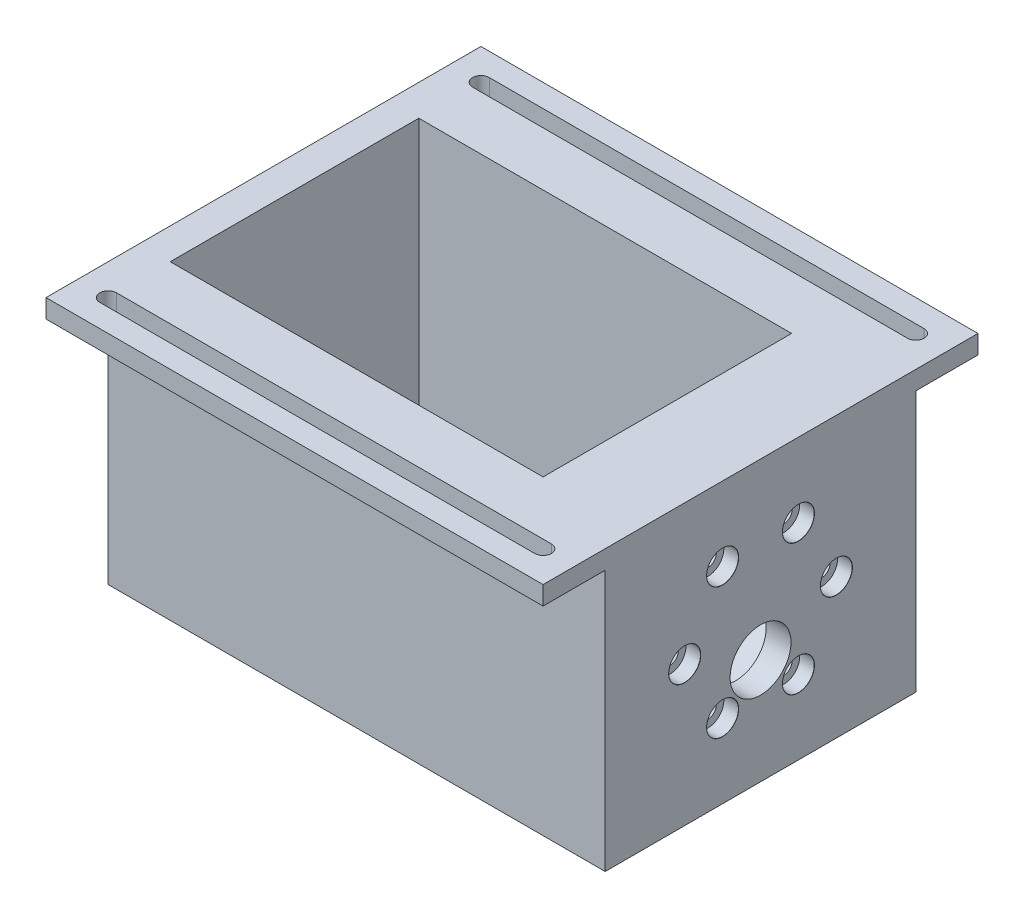
from build123d import *

# Parameters (mm, degrees)
SKETCH1_W                     = 101.6
SKETCH1_H                     = 63.5
BOSS_EXTRUDE1_DEPTH           = 57.15
CBORE_FOR_M3_SHCS1_AT_2_COUNT = 2
CBORE_FOR_M3_SHCS1_AT_2_PITCH = 15.499969
CBORE_FOR_M3_SHCS1_AT_3_COUNT = 2
CBORE_FOR_M3_SHCS1_AT_3_PITCH = 26.846733824
CBORE_FOR_M3_SHCS1_AT_4_COUNT = 2
CBORE_FOR_M3_SHCS1_AT_4_PITCH = 30.999938
CBORE_FOR_M3_SHCS1_AT_5_COUNT = 2
CBORE_FOR_M3_SHCS1_AT_5_PITCH = 26.846733824
CBORE_FOR_M3_SHCS1_AT_6_COUNT = 2
CBORE_FOR_M3_SHCS1_AT_6_PITCH = 15.499969
SKETCH8_R                     = 6.223
CUT_EXTRUDE1_DEPTH            = 50.8
SKETCH9_W                     = 76.2
SKETCH9_H                     = 50.8
CUT_EXTRUDE2_DEPTH            = 53.34
CUT_EXTRUDE3_START            = -19.05
SKETCH2_R                     = 18.542
CUT_EXTRUDE3_DEPTH            = 13.97
SKETCH10_W                    = 101.6
SKETCH10_H                    = 12.7
BOSS_EXTRUDE2_DEPTH           = 3.81
CUT_EXTRUDE4_DEPTH            = 3.81


with BuildPart() as part:
    # Sketch1 → Boss-Extrude1 (new body)
    with BuildSketch(Plane(origin=(0, 0, 0), x_dir=(1, 0, 0), z_dir=(0, 1, 0))):
        Rectangle(SKETCH1_W, SKETCH1_H)
    extrude(amount=BOSS_EXTRUDE1_DEPTH)

    # Sketch6 → CBORE for M3 SHCS1 (revolve, cut)
    with BuildSketch(Plane(origin=(50.8, 41.998366912, 7.7499845), x_dir=(0, 0, -1), z_dir=(0, 1, 0))):
        Polygon((0, 0), (0, 6.101463052), (1.7, 5.08), (1.7, 3), (3.25, 3), (3.25, 0.025), (3.275, 0), align=None)
    cbore_for_m3_shcs1 = revolve(axis=Axis((57.15, 41.998366912, 7.7499845), (-1, 0, 0)), mode=Mode.SUBTRACT)

    # CBORE for M3 SHCS1 at 2: CBORE for M3 SHCS1 ×2
    with Locations(*[Vector(0, -0.866025404, 0.5) * (i * CBORE_FOR_M3_SHCS1_AT_2_PITCH) for i in range(1, CBORE_FOR_M3_SHCS1_AT_2_COUNT)]):
        add(cbore_for_m3_shcs1, mode=Mode.SUBTRACT)

    # CBORE for M3 SHCS1 at 3: CBORE for M3 SHCS1 ×2
    with Locations(*[(0, -i * CBORE_FOR_M3_SHCS1_AT_3_PITCH, 0) for i in range(1, CBORE_FOR_M3_SHCS1_AT_3_COUNT)]):
        add(cbore_for_m3_shcs1, mode=Mode.SUBTRACT)

    # CBORE for M3 SHCS1 at 4: CBORE for M3 SHCS1 ×2
    with Locations(*[Vector(0, -0.866025404, -0.5) * (i * CBORE_FOR_M3_SHCS1_AT_4_PITCH) for i in range(1, CBORE_FOR_M3_SHCS1_AT_4_COUNT)]):
        add(cbore_for_m3_shcs1, mode=Mode.SUBTRACT)

    # CBORE for M3 SHCS1 at 5: CBORE for M3 SHCS1 ×2
    with Locations(*[Vector(0, -0.5, -0.866025404) * (i * CBORE_FOR_M3_SHCS1_AT_5_PITCH) for i in range(1, CBORE_FOR_M3_SHCS1_AT_5_COUNT)]):
        add(cbore_for_m3_shcs1, mode=Mode.SUBTRACT)

    # CBORE for M3 SHCS1 at 6: CBORE for M3 SHCS1 ×2
    with Locations(*[(0, 0, -i * CBORE_FOR_M3_SHCS1_AT_6_PITCH) for i in range(1, CBORE_FOR_M3_SHCS1_AT_6_COUNT)]):
        add(cbore_for_m3_shcs1, mode=Mode.SUBTRACT)

    # Sketch8 → Cut-Extrude1 (cut)
    with BuildSketch(Plane(origin=(50.8, 29.820388237, 44.133609073), x_dir=(0, 0, 1), z_dir=(1, 0, 0))):
        with Locations((-44.133609073, 8.245386937)):
            Circle(SKETCH8_R)
    extrude(amount=-CUT_EXTRUDE1_DEPTH, mode=Mode.SUBTRACT)

    # Sketch9 → Cut-Extrude2 (cut)
    with BuildSketch(Plane(origin=(0, 57.15, 0), x_dir=(1, 0, 0), z_dir=(0, 1, 0))):
        with Locations((-6.35, 0)):
            Rectangle(SKETCH9_W, SKETCH9_H)
    extrude(amount=-CUT_EXTRUDE2_DEPTH, mode=Mode.SUBTRACT)

    # Sketch2 → Cut-Extrude3 (cut)
    with BuildSketch(Plane(origin=(50.8, 29.820388237, 50.894246884), x_dir=(0, 0, -1), z_dir=(1, 0, 0)).offset(CUT_EXTRUDE3_START)):
        with Locations((50.894246884, -1.245388237)):
            Circle(SKETCH2_R)
    extrude(amount=CUT_EXTRUDE3_DEPTH, mode=Mode.SUBTRACT)

    # Sketch10 → Boss-Extrude2 (add)
    with BuildSketch(Plane(origin=(0, 57.15, 0), x_dir=(1, 0, 0), z_dir=(0, 1, 0))):
        with Locations((0, 38.1)):
            Rectangle(SKETCH10_W, SKETCH10_H)
        with Locations((0, -38.1)):
            Rectangle(SKETCH10_W, SKETCH10_H)
    extrude(amount=-BOSS_EXTRUDE2_DEPTH)

    # Sketch11 → Cut-Extrude4 (cut)
    with BuildSketch(Plane(origin=(0, 57.15, 0), x_dir=(1, 0, 0), z_dir=(0, 1, 0))):
        with BuildLine():
            Line((-44.45, 39.8018), (44.45, 39.8018))
            ThreePointArc((44.45, 39.8018), (46.1518, 38.1), (44.45, 36.3982))
            Line((44.45, 36.3982), (-44.45, 36.3982))
            ThreePointArc((-44.45, 36.3982), (-46.1518, 38.1), (-44.45, 39.8018))
        make_face()
        with BuildLine():
            Line((-44.45, -39.8018), (44.45, -39.8018))
            ThreePointArc((44.45, -39.8018), (46.1518, -38.1), (44.45, -36.3982))
            Line((44.45, -36.3982), (-44.45, -36.3982))
            ThreePointArc((-44.45, -36.3982), (-46.1518, -38.1), (-44.45, -39.8018))
        make_face()
    extrude(amount=-CUT_EXTRUDE4_DEPTH, mode=Mode.SUBTRACT)


solid = part.part
